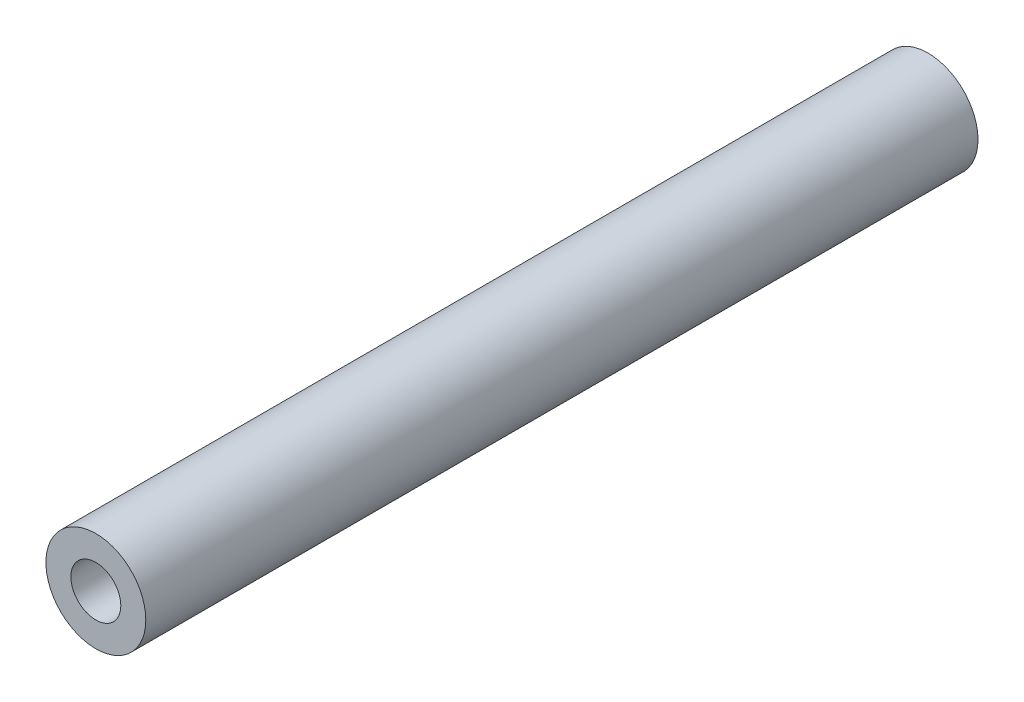
from build123d import *

# Parameters (mm, degrees)
SKETCH_2_R      = 30
SKETCH_2_R_2    = 15
EXTRUDE_1_DEPTH = 500


with BuildPart() as part:
    # 草图2 → 凸台-拉伸1 (new body)
    with BuildSketch(Plane.XY):
        with Locations((-223.055584672, 347.74846745)):
            Circle(SKETCH_2_R)
        with Locations((-223.055584672, 347.74846745)):
            Circle(SKETCH_2_R_2, mode=Mode.SUBTRACT)
    extrude(amount=EXTRUDE_1_DEPTH)


solid = part.part
